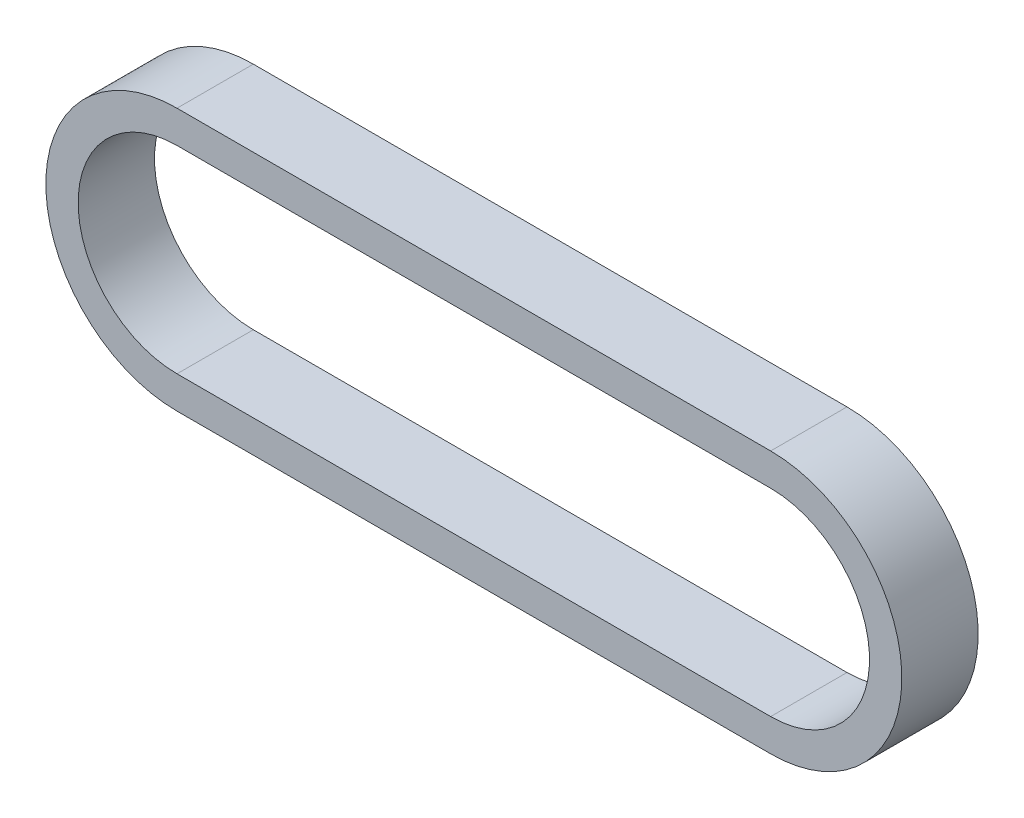
from build123d import *

# Parameters (mm, degrees)
EXTRUDE_THIN1_DEPTH = 4.5


with BuildPart() as part:
    # Sketch1 → Extrude-Thin1 (new body, symmetric)
    with BuildSketch(Plane.XY):
        with BuildLine():
            Line((69.999999954, -15.466956708), (0, -15.466956708))
            ThreePointArc((0, -15.466956708), (-15.466956708, 0), (0, 15.466956708))
            Line((0, 15.466956708), (69.999999954, 15.466956708))
            ThreePointArc((69.999999954, 15.466956708), (85.466956662, 0), (69.999999954, -15.466956708))
        make_face()
        with BuildLine():
            Line((69.999999954, -11.656956708), (0, -11.656956708))
            ThreePointArc((0, -11.656956708), (-11.656956708, 0), (0, 11.656956708))
            Line((0, 11.656956708), (69.999999954, 11.656956708))
            ThreePointArc((69.999999954, 11.656956708), (81.656956662, 0), (69.999999954, -11.656956708))
        make_face(mode=Mode.SUBTRACT)
    extrude(amount=EXTRUDE_THIN1_DEPTH, both=True)


solid = part.part
